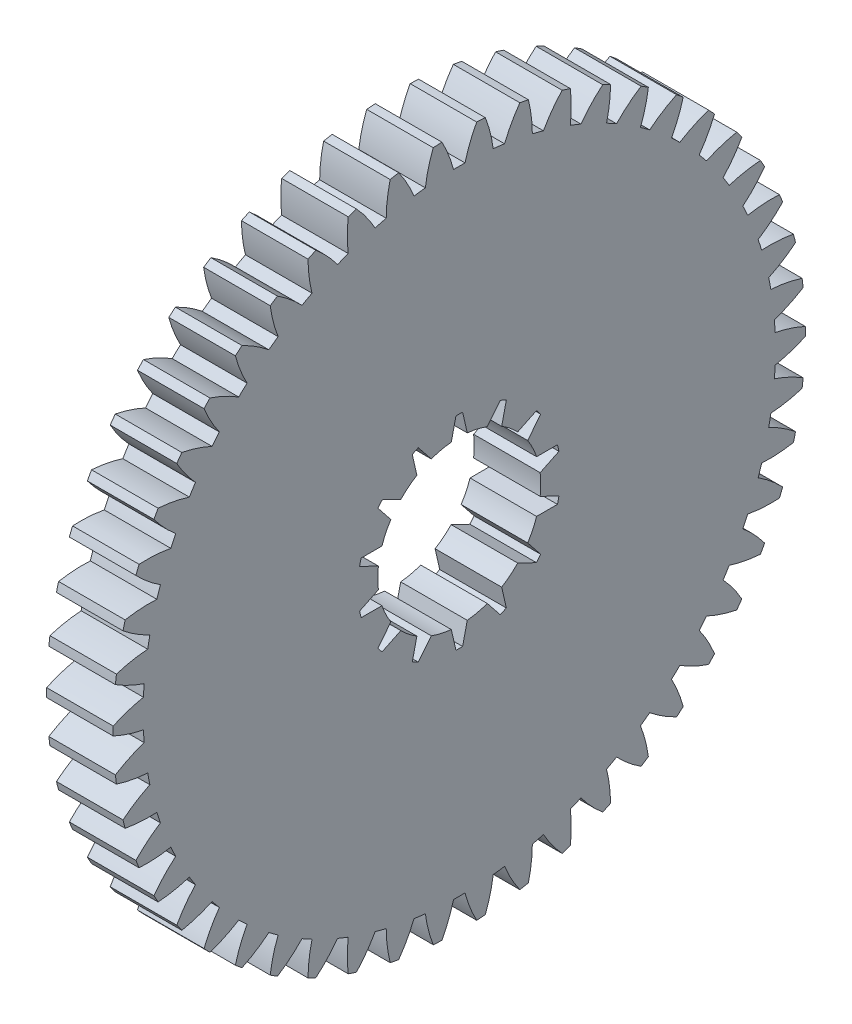
from build123d import *

# Parameters (mm, degrees)
BASPROSKE_W             = 10
BASPROSKE_H             = 52
TOOTHCUT_DEPTH          = 75.215901261
TEETHCUTS_COUNT         = 50
TEETHCUTS_ANGLE         = 352.8
BORSKE_R                = 10
BORE_DEPTH              = 50.0000508
ENL_V_MAT_EXTRU_1_DEPTH = 10


with BuildPart() as part:
    # BasProSke → Base-Revolve (revolve)
    with BuildSketch(Plane(origin=(0, 0, 0), x_dir=(1, 0, 0), z_dir=(0, 1, 0)), mode=Mode.PRIVATE) as base_revolve_sk:
        with Locations((5, 26)):
            Rectangle(BASPROSKE_W, BASPROSKE_H)
    revolve(base_revolve_sk.sketch.rotate(Axis((-10, 0, 0), (1, 0, 0)), 180), axis=Axis((-10, 0, 0), (1, 0, 0)))

    # TooCutSke → ToothCut (cut, through all)
    with BuildSketch(Plane(origin=(0, 0, 0), x_dir=(0, 0, -1), z_dir=(1, 0, 0))):
        with BuildLine():
            ThreePointArc((0.86062222, 47.491202663), (0, 47.499), (-0.86062222, 47.491202663))
            ThreePointArc((-0.86062222, 47.491202663), (-1.610166517, 49.778366785), (-2.629027787, 51.958930494))
            ThreePointArc((-2.629027787, 51.958930494), (0, 52.0254), (2.629027787, 51.958930494))
            ThreePointArc((2.629027787, 51.958930494), (1.610166517, 49.778366785), (0.86062222, 47.491202663))
        make_face()
    toothcut = extrude(amount=TOOTHCUT_DEPTH, mode=Mode.SUBTRACT)

    # TeethCuts: ToothCut ×50 about axis
    teethcuts_axis = Axis((-10, 0, 0), (1, 0, 0))
    for i in range(1, TEETHCUTS_COUNT):
        add(toothcut.rotate(teethcuts_axis, i * TEETHCUTS_ANGLE / (TEETHCUTS_COUNT - 1)), mode=Mode.SUBTRACT)

    # BorSke → Bore (cut, symmetric)
    with BuildSketch(Plane(origin=(0, 0, 0), x_dir=(0, 0, -1), z_dir=(1, 0, 0))):
        with Locations(Location((0, 0, 0), (0, 0, 180))):
            Circle(BORSKE_R)
    extrude(amount=BORE_DEPTH, both=True, mode=Mode.SUBTRACT)

    # Esquisse1 → Enlèv. mat.-Extru.1 (cut)
    with BuildSketch(Plane(origin=(10, 0, 0), x_dir=(0, 0, -1), z_dir=(1, 0, 0))):
        with BuildLine():
            Line((-0.5, 15.241801075), (-1.2, 12.191082807))
            ThreePointArc((-1.2, 12.191082807), (-2.725881441, 11.942866924), (-4.208349951, 11.504446562))
            Line((-4.208349951, 11.504446562), (-6.162685207, 13.949330129))
            ThreePointArc((-6.162685207, 13.949330129), (-6.616727022, 13.739775236), (-7.063654075, 13.515446389))
            Line((-7.063654075, 13.515446389), (-6.370675234, 10.463125588))
            ThreePointArc((-6.370675234, 10.463125588), (-7.637750073, 9.57743566), (-8.783184581, 8.539213583))
            Line((-8.783184581, 8.539213583), (-11.604775029, 9.894023273))
            ThreePointArc((-11.604775029, 9.894023273), (-11.922930108, 9.508219478), (-12.228264831, 9.112191791))
            Line((-12.228264831, 9.112191791), (-10.279560106, 6.662818025))
            ThreePointArc((-10.279560106, 6.662818025), (-11.036868632, 5.315075804), (-11.618401787, 3.882684627))
            Line((-11.618401787, 3.882684627), (-14.748396833, 3.879083766))
            ThreePointArc((-14.748396833, 3.879083766), (-14.867650661, 3.393444243), (-14.970917767, 2.904155854))
            Line((-14.970917767, 2.904155854), (-12.152452029, 1.542857637))
            ThreePointArc((-12.152452029, 1.542857637), (-12.25, 0), (-12.152452029, -1.542857637))
            Line((-12.152452029, -1.542857637), (-14.970917767, -2.904155854))
            ThreePointArc((-14.970917767, -2.904155854), (-14.867650661, -3.393444243), (-14.748396833, -3.879083766))
            Line((-14.748396833, -3.879083766), (-11.618401787, -3.882684627))
            ThreePointArc((-11.618401787, -3.882684627), (-11.036868632, -5.315075804), (-10.279560106, -6.662818025))
            Line((-10.279560106, -6.662818025), (-12.228264831, -9.112191791))
            ThreePointArc((-12.228264831, -9.112191791), (-11.922930108, -9.508219478), (-11.604775029, -9.894023273))
            Line((-11.604775029, -9.894023273), (-8.783184581, -8.539213583))
            ThreePointArc((-8.783184581, -8.539213583), (-7.637750073, -9.57743566), (-6.370675234, -10.463125588))
            Line((-6.370675234, -10.463125588), (-7.063654075, -13.515446389))
            ThreePointArc((-7.063654075, -13.515446389), (-6.616727022, -13.739775236), (-6.162685207, -13.949330129))
            Line((-6.162685207, -13.949330129), (-4.208349951, -11.504446562))
            ThreePointArc((-4.208349951, -11.504446562), (-2.725881441, -11.942866924), (-1.2, -12.191082807))
            Line((-1.2, -12.191082807), (-0.5, -15.241801075))
            ThreePointArc((-0.5, -15.241801075), (0, -15.25), (0.5, -15.241801075))
            Line((0.5, -15.241801075), (1.2, -12.191082807))
            ThreePointArc((1.2, -12.191082807), (2.725881441, -11.942866924), (4.208349951, -11.504446562))
            Line((4.208349951, -11.504446562), (6.162685207, -13.949330129))
            ThreePointArc((6.162685207, -13.949330129), (6.616727022, -13.739775236), (7.063654075, -13.515446389))
            Line((7.063654075, -13.515446389), (6.370675234, -10.463125588))
            ThreePointArc((6.370675234, -10.463125588), (7.637750073, -9.57743566), (8.783184581, -8.539213583))
            Line((8.783184581, -8.539213583), (11.604775029, -9.894023273))
            ThreePointArc((11.604775029, -9.894023273), (11.922930108, -9.508219478), (12.228264831, -9.112191791))
            Line((12.228264831, -9.112191791), (10.279560106, -6.662818025))
            ThreePointArc((10.279560106, -6.662818025), (11.036868632, -5.315075804), (11.618401787, -3.882684627))
            Line((11.618401787, -3.882684627), (14.748396833, -3.879083766))
            ThreePointArc((14.748396833, -3.879083766), (14.867650661, -3.393444243), (14.970917767, -2.904155854))
            Line((14.970917767, -2.904155854), (12.152452029, -1.542857637))
            ThreePointArc((12.152452029, -1.542857637), (12.25, 0), (12.152452029, 1.542857637))
            Line((12.152452029, 1.542857637), (14.970917767, 2.904155854))
            ThreePointArc((14.970917767, 2.904155854), (14.867650661, 3.393444243), (14.748396833, 3.879083766))
            Line((14.748396833, 3.879083766), (11.618401787, 3.882684627))
            ThreePointArc((11.618401787, 3.882684627), (11.036868632, 5.315075804), (10.279560106, 6.662818025))
            Line((10.279560106, 6.662818025), (12.228264831, 9.112191791))
            ThreePointArc((12.228264831, 9.112191791), (11.922930108, 9.508219478), (11.604775029, 9.894023273))
            Line((11.604775029, 9.894023273), (8.783184581, 8.539213583))
            ThreePointArc((8.783184581, 8.539213583), (7.637750073, 9.57743566), (6.370675234, 10.463125588))
            Line((6.370675234, 10.463125588), (7.063654075, 13.515446389))
            ThreePointArc((7.063654075, 13.515446389), (6.616727022, 13.739775236), (6.162685207, 13.949330129))
            Line((6.162685207, 13.949330129), (4.208349951, 11.504446562))
            ThreePointArc((4.208349951, 11.504446562), (2.725881441, 11.942866924), (1.2, 12.191082807))
            Line((1.2, 12.191082807), (0.5, 15.241801075))
            ThreePointArc((0.5, 15.241801075), (0, 15.25), (-0.5, 15.241801075))
        make_face()
    extrude(amount=-ENL_V_MAT_EXTRU_1_DEPTH, mode=Mode.SUBTRACT)


solid = part.part
